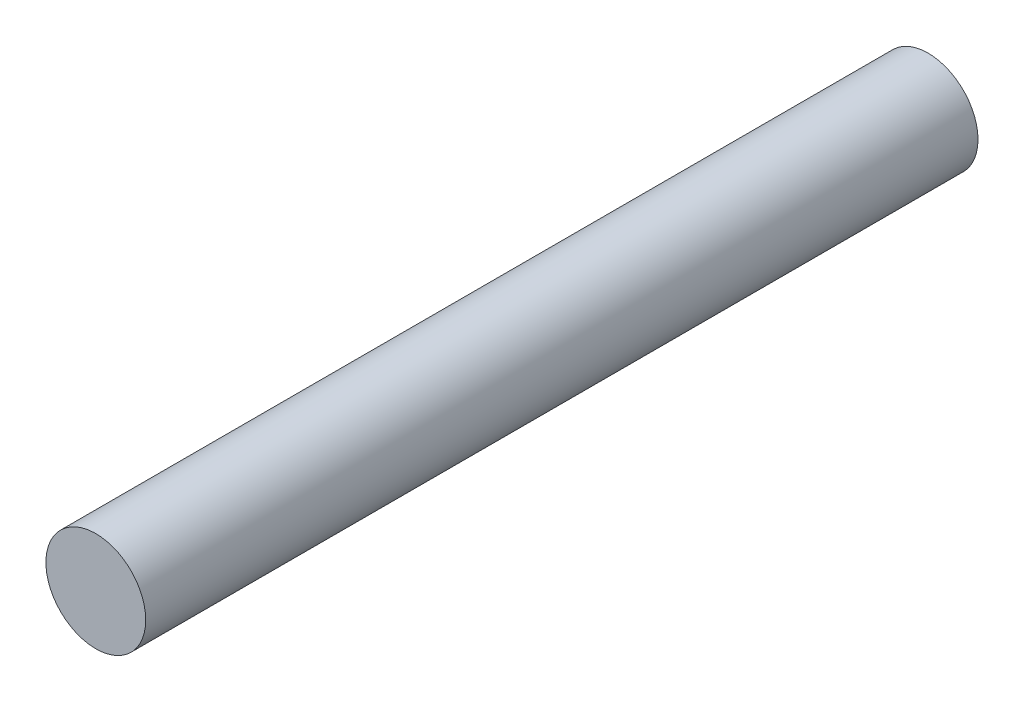
from build123d import *

# Parameters (mm, degrees)
SKETCH1_R           = 3
BOSS_EXTRUDE1_DEPTH = 50.038


with BuildPart() as part:
    # Sketch1 → Boss-Extrude1 (new body)
    with BuildSketch(Plane.XY):
        Circle(SKETCH1_R)
    extrude(amount=BOSS_EXTRUDE1_DEPTH)


solid = part.part
